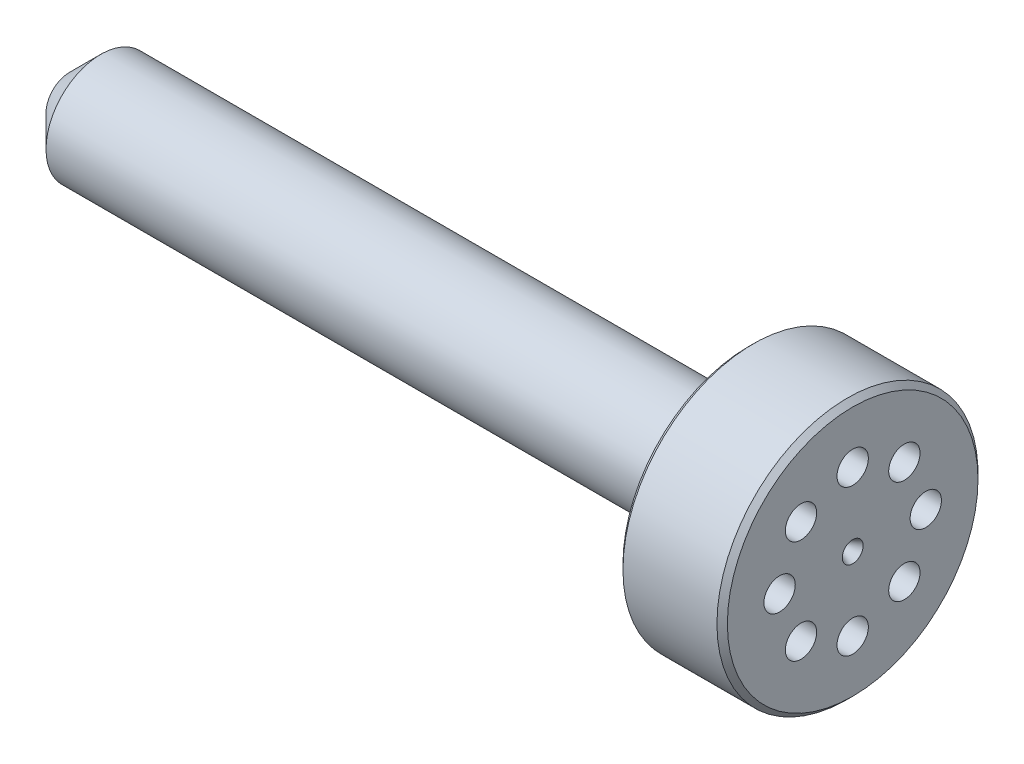
from build123d import *

# Parameters (mm, degrees)
CHAMFER1_SIZE      = 0.5
SKETCH3_R          = 1.5
CUT_EXTRUDE1_DEPTH = 76


with BuildPart() as part:
    # Sketch2 → Revolve1 (revolve)
    with BuildSketch(Plane(origin=(0, 0, 0), x_dir=(1, 0, 0), z_dir=(0, 1, 0))):
        Polygon((-34, 1), (-34, 2.25), (-31, 5.25), (31, 5.25), (31, 12.5), (41, 12.5), (41, 1), (39, 0), (-32, 0), align=None)
    revolve(axis=Axis((-32, 0, 0), (1, 0, 0)))

    # Chamfer1
    chamfer1_edges = [part.edges().sort_by_distance(p)[0] for p in [
        (41, 0, 12.5),
        (31, 0, 12.5),
    ]]
    chamfer(chamfer1_edges, length=CHAMFER1_SIZE)

    # Sketch3 → Cut-Extrude1 (cut, through all)
    with BuildSketch(Plane(origin=(41, 0, 0), x_dir=(0, 0, -1), z_dir=(1, 0, 0))):
        with Locations((0, 7)):
            Circle(SKETCH3_R)
        with Locations((4.949747468, 4.949747468)):
            Circle(SKETCH3_R)
        with Locations((7, 0)):
            Circle(SKETCH3_R)
        with Locations((4.949747468, -4.949747468)):
            Circle(SKETCH3_R)
        with Locations((0, -7)):
            Circle(SKETCH3_R)
        with Locations((-4.949747468, -4.949747468)):
            Circle(SKETCH3_R)
        with Locations((-7, 0)):
            Circle(SKETCH3_R)
        with Locations((-4.949747468, 4.949747468)):
            Circle(SKETCH3_R)
    extrude(amount=-CUT_EXTRUDE1_DEPTH, mode=Mode.SUBTRACT)


solid = part.part
